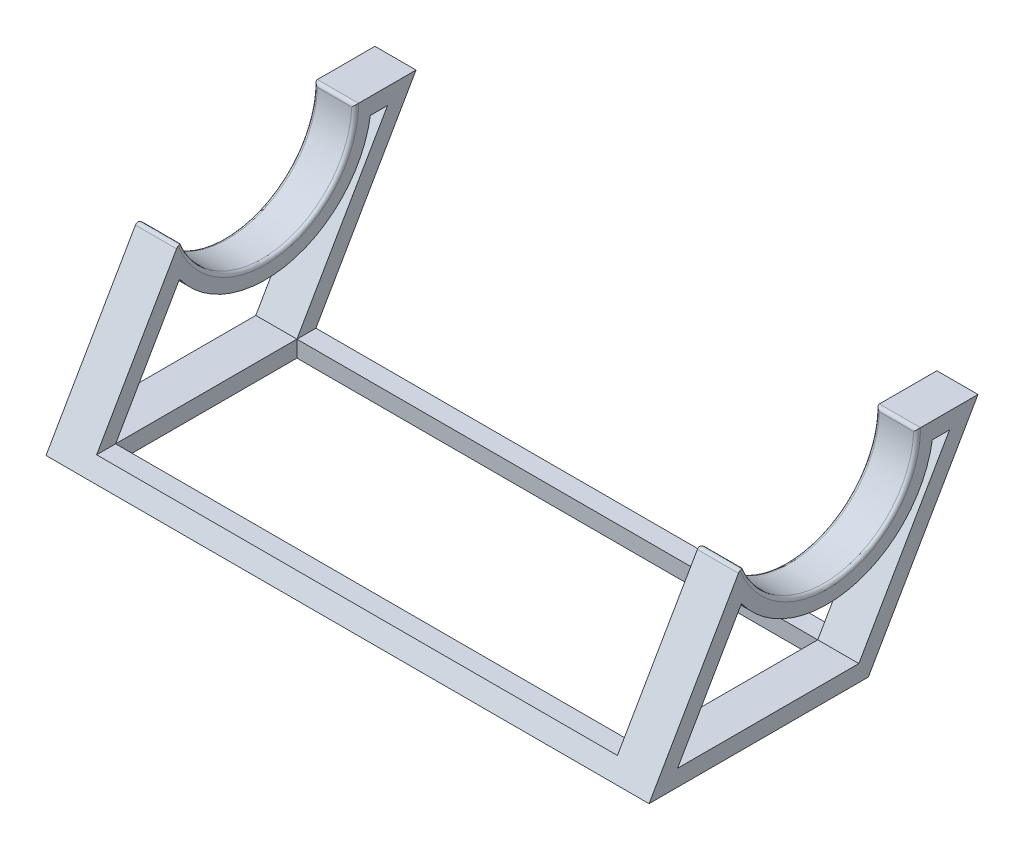
from build123d import *

# Parameters (mm, degrees)
BOSS_EXTRUDE1_DEPTH = 279.4
SKETCH2_W           = 241.3
SKETCH2_H           = 124.206
SKETCH2_H_2         = 28.194
CUT_EXTRUDE3_DEPTH  = 80.368181
FILLET1_R           = 1.5875
SKETCH4_W           = 241.3
SKETCH4_H           = 84.002363795
CUT_EXTRUDE5_DEPTH  = 7.62


with BuildPart() as part:
    # Sketch1 → Boss-Extrude1 (new body)
    with BuildSketch(Plane(origin=(0, 0, 0), x_dir=(0, 0, -1), z_dir=(1, 0, 0))):
        with BuildLine():
            Line((0, 0), (101.6, 0))
            Line((101.6, 0), (152.4, 87.988181024))
            Line((152.4, 87.988181024), (124.206, 87.988181024))
            ThreePointArc((124.206, 87.988181024), (89.315487923, 46.885255226), (43.091610276, 74.636858378))
            Line((43.091610276, 74.636858378), (0, 0))
        make_face()
        with BuildLine():
            Line((139.201772846, 80.368181024), (131.23325971, 80.368181024))
            ThreePointArc((131.23325971, 80.368181024), (94.185048049, 40.105513671), (42.791899046, 58.8777433))
            Line((42.791899046, 58.8777433), (13.198227154, 7.62))
            Line((13.198227154, 7.62), (97.200590949, 7.62))
            Line((97.200590949, 7.62), (139.201772846, 80.368181024))
        make_face(mode=Mode.SUBTRACT)
    extrude(amount=BOSS_EXTRUDE1_DEPTH)

    # Sketch2 → Cut-Extrude3 (cut)
    with BuildSketch(Plane(origin=(0, 87.988181024, 0), x_dir=(1, 0, 0), z_dir=(0, 1, 0))):
        with Locations((139.7, 62.103)):
            Rectangle(SKETCH2_W, SKETCH2_H)
        with Locations((139.7, 138.303)):
            Rectangle(SKETCH2_W, SKETCH2_H_2)
    extrude(amount=-CUT_EXTRUDE3_DEPTH, mode=Mode.SUBTRACT)

    # Fillet1
    fillet1_edges = [part.edges().sort_by_distance(p)[0] for p in [
        (279.4, 46.885255226, -89.315487923),
        (9.525, 74.636858378, -43.091610276),
        (9.525, 87.988181024, -124.206),
        (19.05, 46.885255226, -89.315487923),
        (260.35, 46.885255226, -89.315487923),
        (0, 46.885255226, -89.315487923),
        (269.875, 74.636858378, -43.091610276),
        (269.875, 87.988181024, -124.206),
    ]]
    fillet(fillet1_edges, radius=FILLET1_R)

    # Sketch4 → Cut-Extrude5 (cut)
    with BuildSketch(Plane(origin=(0, 7.62, 0), x_dir=(1, 0, 0), z_dir=(0, 1, 0))):
        with Locations((139.7, 55.199409051)):
            Rectangle(SKETCH4_W, SKETCH4_H)
    extrude(amount=-CUT_EXTRUDE5_DEPTH, mode=Mode.SUBTRACT)


solid = part.part
